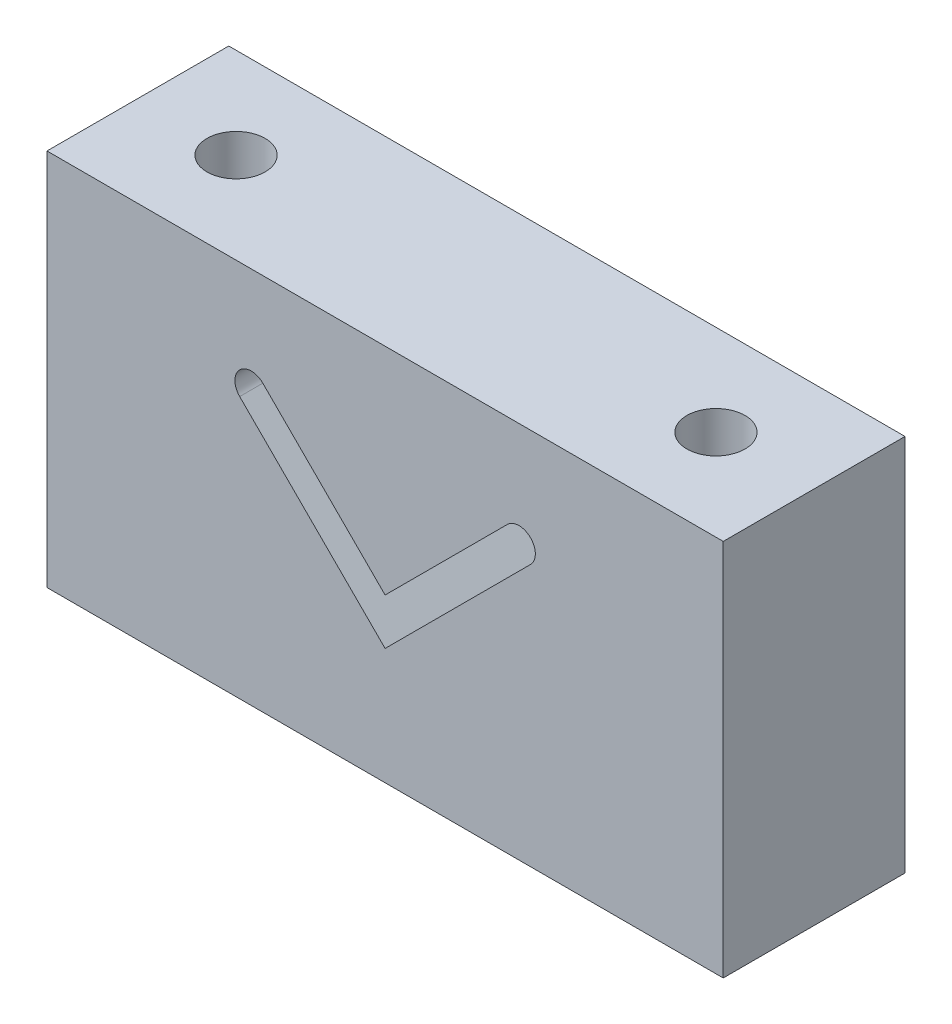
from build123d import *

# Parameters (mm, degrees)
SKETCH1_W           = 93
SKETCH1_H           = 52
BOSS_EXTRUDE1_DEPTH = 25
CUT_EXTRUDE1_DEPTH  = 26
SKETCH3_R           = 4
CUT_EXTRUDE2_DEPTH  = 53


with BuildPart() as part:
    # Sketch1 → Boss-Extrude1 (new body)
    with BuildSketch(Plane.XY):
        Rectangle(SKETCH1_W, SKETCH1_H)
    extrude(amount=BOSS_EXTRUDE1_DEPTH)

    # Sketch2 → Cut-Extrude1 (cut, through all)
    with BuildSketch(Plane(origin=(0, 0, 0), x_dir=(-1, 0, 0), z_dir=(0, 0, -1))):
        with BuildLine():
            Line((0, -10), (20, 10))
            ThreePointArc((20, 10), (20, 13.181980515), (16.818019485, 13.181980515))
            Line((16.818019485, 13.181980515), (0, -3.636038969))
            Line((0, -3.636038969), (-16.818019485, 13.181980515))
            ThreePointArc((-16.818019485, 13.181980515), (-20, 13.181980515), (-20, 10))
            Line((-20, 10), (0, -10))
        make_face()
    extrude(amount=-CUT_EXTRUDE1_DEPTH, mode=Mode.SUBTRACT)

    # Sketch3 → Cut-Extrude2 (cut, through all)
    with BuildSketch(Plane.XZ.offset(26)):
        with Locations((-33, 12.5)):
            Circle(SKETCH3_R)
        with Locations((33, 12.5)):
            Circle(SKETCH3_R)
    extrude(amount=-CUT_EXTRUDE2_DEPTH, mode=Mode.SUBTRACT)


solid = part.part
